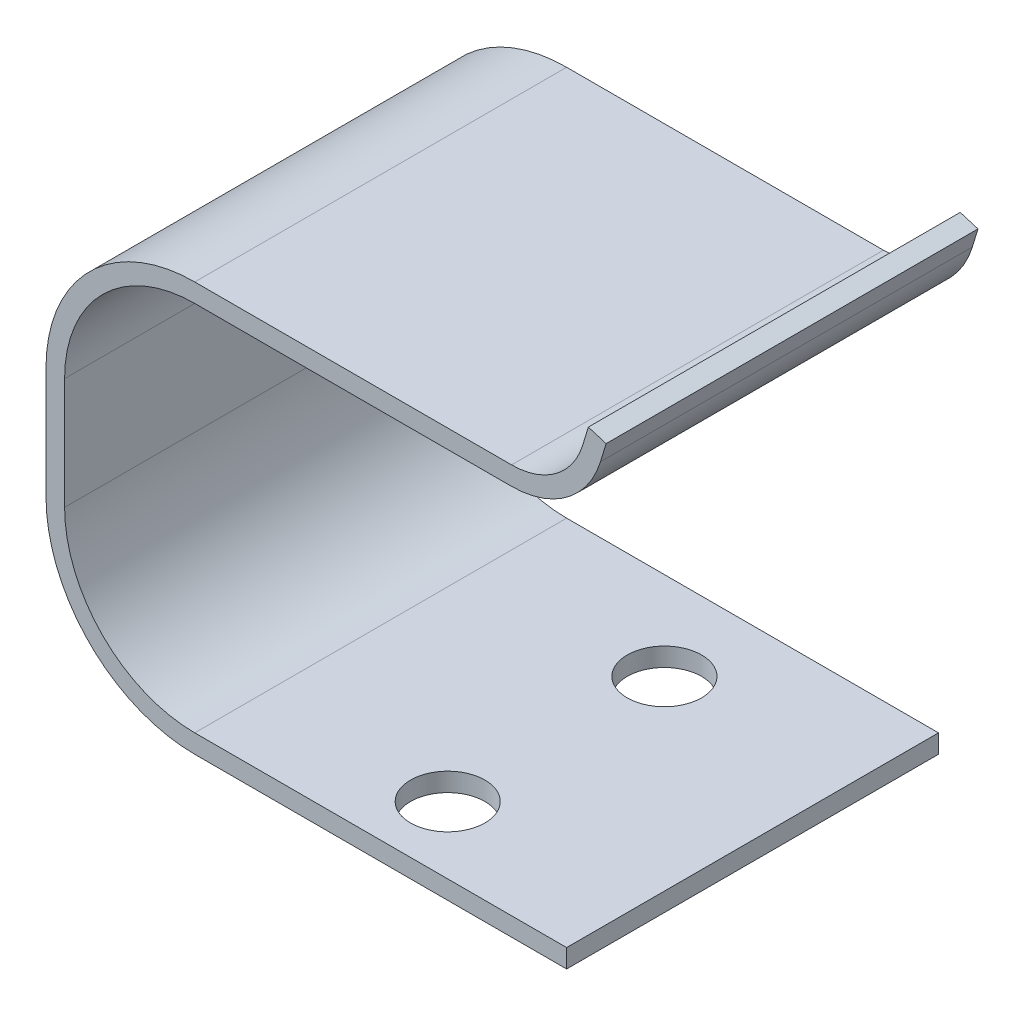
from build123d import *

# Parameters (mm, degrees)
EXTRUS_O_FINA1_DEPTH  = 20
ESBO_O3_R             = 2
CORTE_EXTRUS_O1_DEPTH = 10


with BuildPart() as part:
    # Esboço1 → Extrusão-Fina1 (new body)
    with BuildSketch(Plane.XY):
        with BuildLine():
            Line((0, 0), (-20, 0))
            ThreePointArc((-20, 0), (-25.656854249, 2.343145751), (-28, 8))
            Line((-28, 8), (-28, 14))
            ThreePointArc((-28, 14), (-25.656854249, 19.656854249), (-20, 22))
            Line((-20, 22), (-2.961110141, 22))
            ThreePointArc((-2.961110141, 22), (-0.581161614, 22.785059097), (0.864586792, 24.832077496))
            Line((0.864586792, 24.832077496), (1.167922504, 25.825696933))
            Line((1.167922504, 25.825696933), (2.124346737, 25.533716307))
            Line((2.124346737, 25.533716307), (1.821011026, 24.54009687))
            ThreePointArc((1.821011026, 24.54009687), (0.013825518, 21.981323872), (-2.961110141, 21))
            Line((-2.961110141, 21), (-20, 21))
            ThreePointArc((-20, 21), (-24.949747468, 18.949747468), (-27, 14))
            Line((-27, 14), (-27, 8))
            ThreePointArc((-27, 8), (-24.949747468, 3.050252532), (-20, 1))
            Line((-20, 1), (0, 1))
            Line((0, 1), (0, 0))
        make_face()
    extrude(amount=EXTRUS_O_FINA1_DEPTH)

    # Esboço3 → Corte-extrusão1 (cut)
    with BuildSketch(Plane.XZ):
        with Locations((-10, 16.395406789)):
            Circle(ESBO_O3_R)
        with Locations((-10, 4.741554418)):
            Circle(ESBO_O3_R)
    extrude(amount=-CORTE_EXTRUS_O1_DEPTH, mode=Mode.SUBTRACT)


solid = part.part
